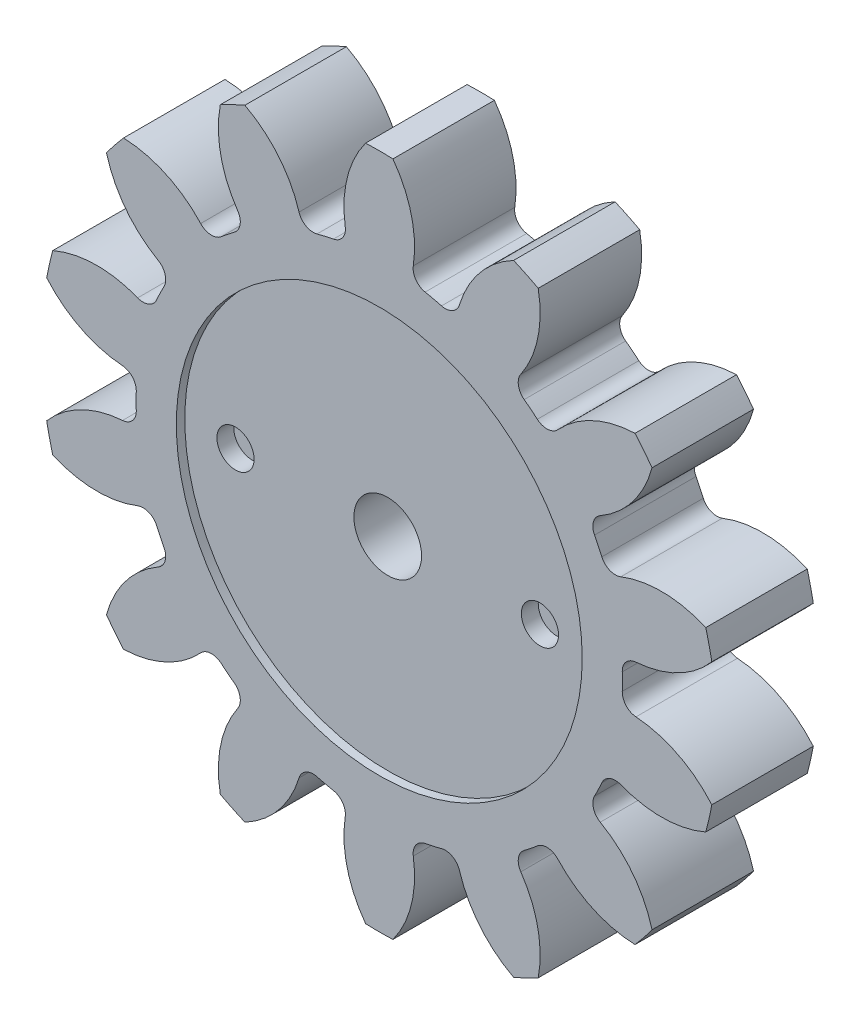
from build123d import *

# Parameters (mm, degrees)
BOSS_EXTRU_1_DEPTH                 = 6
CONG_1_R                           = 0.875
R_P_TITION_CIRCULAIRE4_COUNT       = 14
CONG_1_OF_R_P_TITION_CIRCULAIRE4_R = 0.875
ESQUISSE6_R                        = 12
ENL_V_MAT_EXTRU_1_DEPTH            = 0.5
ESQUISSE7_R                        = 2
ENL_V_MAT_EXTRU_2_DEPTH            = 6.5000001
ESQUISSE8_R                        = 1.1
ENL_V_MAT_EXTRU_3_DEPTH            = 1


with BuildPart() as part:
    # Esquisse3 → Boss.-Extru.1 (new body)
    with BuildSketch(Plane.XY):
        with BuildLine():
            Line((-4.577445339, 13.454236279), (-1.378706913, -0.560352459))
            Line((-1.378706913, -0.560352459), (1.820031512, 13.454236279))
            ThreePointArc((1.820031512, 13.454236279), (1.134989636, 13.593161404), (0.444004358, 13.69862186))
            ThreePointArc((0.444004358, 13.69862186), (0.608952116, 16.680304966), (-0.571450192, 19.423349315))
            ThreePointArc((-0.571450192, 19.423349315), (-1.378706913, 19.439647541), (-2.185963634, 19.423349315))
            ThreePointArc((-2.185963634, 19.423349315), (-3.366365942, 16.680304966), (-3.201418184, 13.69862186))
            ThreePointArc((-3.201418184, 13.69862186), (-3.892403463, 13.593161404), (-4.577445339, 13.454236279))
        make_face()
    boss_extru_1 = extrude(amount=BOSS_EXTRU_1_DEPTH)

    # Cong_1
    cong_1_edges = [part.edges().sort_by_distance(p)[0] for p in [
        (-3.201418184, 13.69862186, 3),
        (0.444004358, 13.69862186, 3),
    ]]
    fillet(cong_1_edges, radius=CONG_1_R)

    # R_p_tition circulaire4: Boss.-Extru.1 ×14 about axis
    r_p_tition_circulaire4_axis = Axis((-1.378706913, -0.560352459, 0), (0, 0, 1))
    for i in range(1, R_P_TITION_CIRCULAIRE4_COUNT):
        add(boss_extru_1.rotate(r_p_tition_circulaire4_axis, i * 360 / R_P_TITION_CIRCULAIRE4_COUNT))

    # Cong_1 of R_p_tition circulaire4
    cong_1_of_r_p_tition_circulaire4_edges = [part.edges().sort_by_distance(p)[0] for p in [
        (-9.207650117, 11.495694709, 3),
        (-5.923237896, 13.077384272, 3),
        (-13.663263833, 6.904919559, 3),
        (-11.390380054, 9.755025669, 3),
        (-15.68577039, 0.83555573, 3),
        (-14.874587561, 4.389579918, 3),
        (-14.874587561, -5.510284835, 3),
        (-15.68577039, -1.956260647, 3),
        (-11.390380054, -10.875730587, 3),
        (-13.663263833, -8.025624476, 3),
        (-5.923237896, -14.19808919, 3),
        (-9.207650117, -12.616399626, 3),
        (0.444004358, -14.819326777, 3),
        (-3.201418184, -14.819326777, 3),
        (6.450236291, -12.616399626, 3),
        (3.16582407, -14.19808919, 3),
        (10.905850006, -8.025624476, 3),
        (8.632966228, -10.875730587, 3),
        (12.928356564, -1.956260647, 3),
        (12.117173735, -5.510284835, 3),
        (12.117173735, 4.389579918, 3),
        (12.928356564, 0.83555573, 3),
        (8.632966228, 9.755025669, 3),
        (10.905850006, 6.904919559, 3),
        (3.16582407, 13.077384272, 3),
        (6.450236291, 11.495694709, 3),
    ]]
    fillet(cong_1_of_r_p_tition_circulaire4_edges, radius=CONG_1_OF_R_P_TITION_CIRCULAIRE4_R)

    # Esquisse6 → Enl_v. mat.-Extru.1 (cut)
    with BuildSketch(Plane.XY.offset(6)):
        with Locations((-1.378706913, -0.560352459)):
            Circle(ESQUISSE6_R)
    extrude(amount=-ENL_V_MAT_EXTRU_1_DEPTH, mode=Mode.SUBTRACT)

    # Esquisse7 → Enl_v. mat.-Extru.2 (cut, through all)
    with BuildSketch(Plane.XY.offset(5.5)):
        with Locations((-1.378706913, -0.560352459)):
            Circle(ESQUISSE7_R)
    extrude(amount=-ENL_V_MAT_EXTRU_2_DEPTH, mode=Mode.SUBTRACT)

    # Esquisse8 → Enl_v. mat.-Extru.3 (cut)
    with BuildSketch(Plane.XY.offset(5.5)):
        with Locations((-10.378706913, -0.560352459)):
            Circle(ESQUISSE8_R)
        with Locations(Location((7.621293087, -0.560352459, 0), (0, 0, 180))):  # turned: the seam where the file's is
            Circle(ESQUISSE8_R)
    extrude(amount=-ENL_V_MAT_EXTRU_3_DEPTH, mode=Mode.SUBTRACT)


solid = part.part
